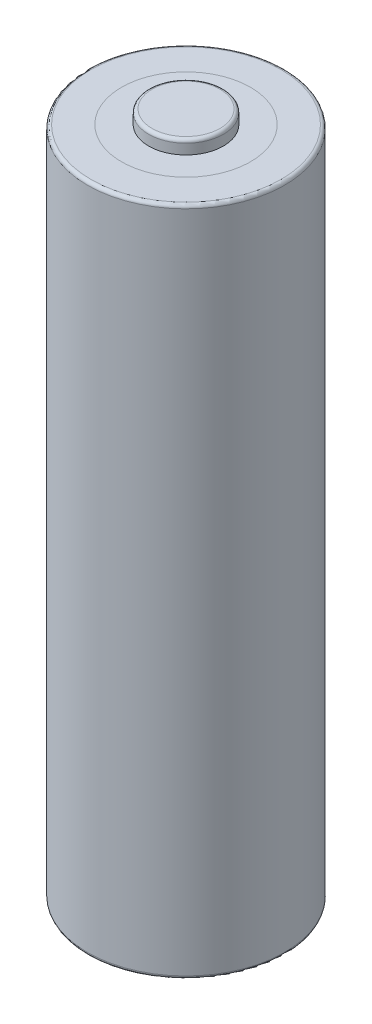
from build123d import *


with BuildPart() as part:
    # Sketch2 → Revolve1 (revolve)
    with BuildSketch(Plane(origin=(0, 0, 0), x_dir=(0, 0, -1), z_dir=(1, 0, 0))):
        with BuildLine():
            Line((0, 0), (0, 50.5))
            Line((0, 50.5), (2.5, 50.5))
            ThreePointArc((2.5, 50.5), (2.676776695, 50.426776695), (2.75, 50.25))
            Line((2.75, 50.25), (2.75, 49.5))
            Line((2.75, 49.5), (7, 49.5))
            ThreePointArc((7, 49.5), (7.176776695, 49.426776695), (7.25, 49.25))
            Line((7.25, 49.25), (7.25, 0.35))
            ThreePointArc((7.25, 0.35), (7.176776695, 0.173223305), (7, 0.1))
            Line((7, 0.1), (3.5, 0.1))
            Line((3.5, 0.1), (3, 0))
            Line((3, 0), (0, 0))
        make_face()
    revolve(axis=Axis((0, 0, 0), (0, -1, 0)))


solid = part.part
